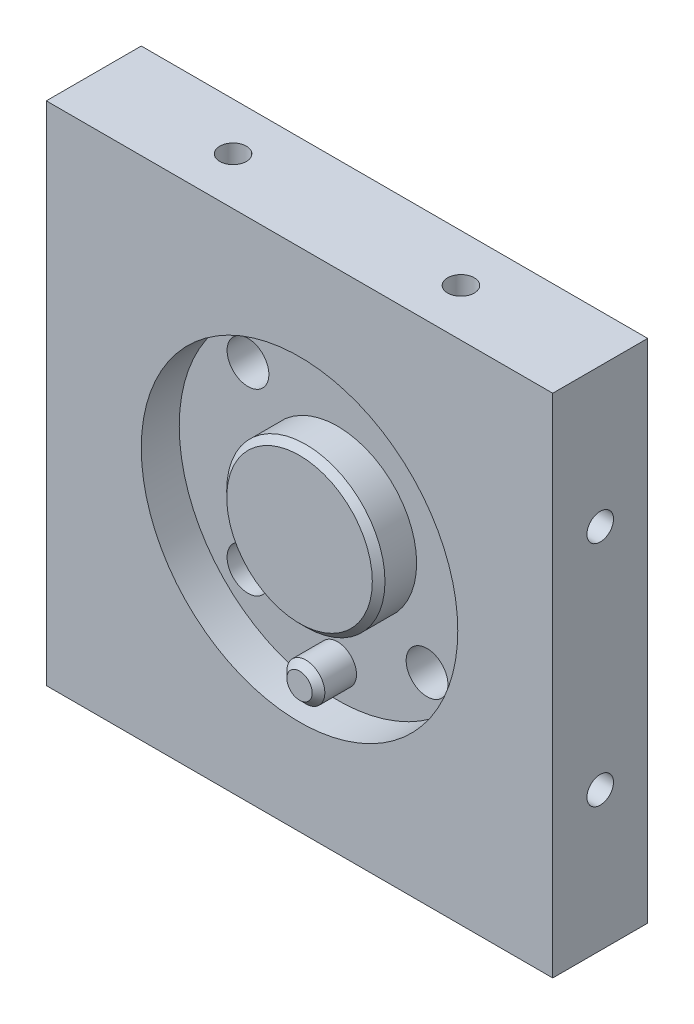
from build123d import *

# Parameters (mm, degrees)
SKETCH6_W                                           = 80
SKETCH6_H                                           = 80
EXTRUDE2_DEPTH                                      = 15
SKETCH7_R                                           = 25
SKETCH7_R_2                                         = 12.5
SKETCH7_R_3                                         = 3
EXTRUDE3_DEPTH                                      = 6
CBORE_FOR_M6_HEX_SOCKET_HEAD_CAP_SCREW1_D           = 6.6
CBORE_FOR_M6_HEX_SOCKET_HEAD_CAP_SCREW1_DEPTH       = 9.001
CBORE_FOR_M6_HEX_SOCKET_HEAD_CAP_SCREW1_CBORE_D     = 11
CBORE_FOR_M6_HEX_SOCKET_HEAD_CAP_SCREW1_CBORE_DEPTH = 2
CIRPATTERN1_COUNT                                   = 4
CHAMFER1_SIZE                                       = 1
M5_TAPPED_HOLE2_AT_2_COUNT                          = 2
M5_TAPPED_HOLE2_AT_2_PITCH                          = 36


with BuildPart() as part:
    # Sketch6 → Extrude2 (new body)
    with BuildSketch(Plane.XY):
        Rectangle(SKETCH6_W, SKETCH6_H)
    extrude(amount=EXTRUDE2_DEPTH)

    # Sketch7 → Extrude3 (cut)
    with BuildSketch(Plane.XY.offset(15)):
        Circle(SKETCH7_R)
        Circle(SKETCH7_R_2, mode=Mode.SUBTRACT)
        with Locations((0, -20)):
            Circle(SKETCH7_R_3, mode=Mode.SUBTRACT)
    extrude(amount=-EXTRUDE3_DEPTH, mode=Mode.SUBTRACT)

    # CBORE for M6 Hex Socket Head Cap Screw1
    with Locations(Plane(origin=(14.142135624, 14.142135624, 0), x_dir=(-1, 0, 0), z_dir=(0, 0, -1))):
        with Locations((0, 0)):
            cbore_for_m6_hex_socket_head_cap_screw1 = CounterBoreHole(CBORE_FOR_M6_HEX_SOCKET_HEAD_CAP_SCREW1_D / 2, CBORE_FOR_M6_HEX_SOCKET_HEAD_CAP_SCREW1_CBORE_D / 2, CBORE_FOR_M6_HEX_SOCKET_HEAD_CAP_SCREW1_CBORE_DEPTH, depth=CBORE_FOR_M6_HEX_SOCKET_HEAD_CAP_SCREW1_DEPTH)

    # CirPattern1: CBORE for M6 Hex Socket Head Cap Screw1 ×4 about axis
    cirpattern1_axis = Axis((0, 0, 0), (0, 0, 1))
    for i in range(1, CIRPATTERN1_COUNT):
        add(cbore_for_m6_hex_socket_head_cap_screw1.rotate(cirpattern1_axis, i * 360 / CIRPATTERN1_COUNT), mode=Mode.SUBTRACT)

    # Chamfer1
    chamfer1_edges = [part.edges().sort_by_distance(p)[0] for p in [
        (-12.5, 0, 15),
        (-3, -20, 15),
    ]]
    chamfer(chamfer1_edges, length=CHAMFER1_SIZE)

    # Sketch11 → M5 Tapped Hole1 (revolve, cut)
    with BuildSketch(Plane(origin=(40, -18, 7.5), x_dir=(0, 0, -1), z_dir=(0, 1, 0))):
        Polygon((0, 0), (0, 13.6618073), (2.1, 12.4), (2.1, 0), align=None)
    m5_tapped_hole1 = revolve(axis=Axis((46.35, -18, 7.5), (-1, 0, 0)), mode=Mode.SUBTRACT)

    # Sketch13 → M5 Tapped Hole2 (revolve, cut)
    with BuildSketch(Plane(origin=(18, -40, 7.5), x_dir=(0, 0, -1), z_dir=(1, 0, 0))):
        Polygon((0, 0), (0, 13.6618073), (2.1, 12.4), (2.1, 0), align=None)
    m5_tapped_hole2 = revolve(axis=Axis((18, -46.35, 7.5), (0, 1, 0)), mode=Mode.SUBTRACT)

    # M5 Tapped Hole2 at 2: M5 Tapped Hole2 ×2
    with Locations(*[(-i * M5_TAPPED_HOLE2_AT_2_PITCH, 0, 0) for i in range(1, M5_TAPPED_HOLE2_AT_2_COUNT)]):
        add(m5_tapped_hole2, mode=Mode.SUBTRACT)

    # Mirror1: M5 Tapped Hole1 across plane
    add(m5_tapped_hole1.mirror(Plane(origin=(0, 0, 0), x_dir=(0, 0, 1), z_dir=(1, 0, 0))), mode=Mode.SUBTRACT)

    # Mirror2: M5 Tapped Hole2, M5 Tapped Hole1 across plane
    add(m5_tapped_hole2.mirror(Plane(origin=(0, 0, 0), x_dir=(0, 0, 1), z_dir=(0, -1, 0))), mode=Mode.SUBTRACT)
    add(m5_tapped_hole1.mirror(Plane(origin=(0, 0, 0), x_dir=(0, 0, 1), z_dir=(0, -1, 0))), mode=Mode.SUBTRACT)

    # Mirror2 copy 1 sketch → Mirror2 copy 1 (revolve, cut)
    with BuildSketch(Plane(origin=(-40, 18, 7.5), x_dir=(0, 0, -1), z_dir=(0, -1, 0))):
        Polygon((0, 0), (0, 13.6618073), (2.1, 12.4), (2.1, 0), align=None)
    revolve(axis=Axis((-46.35, 18, 7.5), (1, 0, 0)), mode=Mode.SUBTRACT)

    # Mirror2 copy 2 sketch → Mirror2 copy 2 (revolve, cut)
    with BuildSketch(Plane(origin=(-18, 40, 7.5), x_dir=(0, 0, -1), z_dir=(1, 0, 0))):
        Polygon((0, 0), (0, -13.6618073), (2.1, -12.4), (2.1, 0), align=None)
    revolve(axis=Axis((-18, 46.35, 7.5), (0, 1, 0)), mode=Mode.SUBTRACT)


solid = part.part
